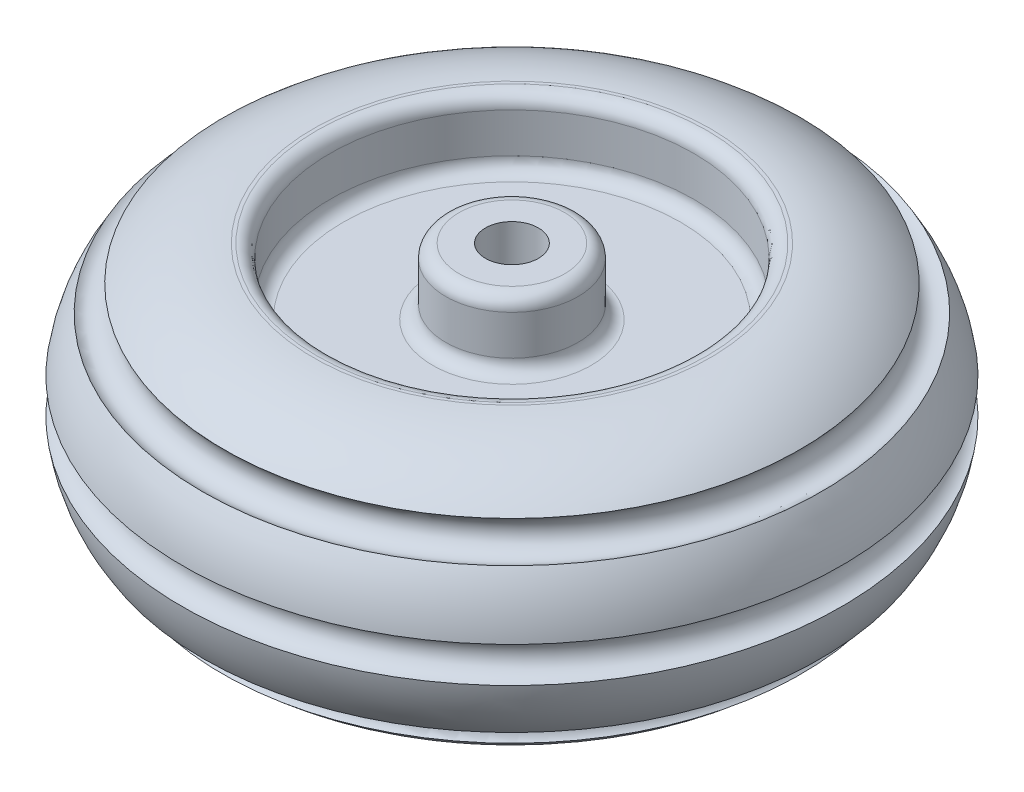
from build123d import *

# Parameters (mm, degrees)
SKETCH3_R          = 20
CUT_EXTRUDE1_DEPTH = 201


with BuildPart() as part:
    # Sketch2 → Revolve2 (revolve)
    with BuildSketch(Plane.XY):
        with BuildLine():
            Line((22.5, -100), (22.5, 100))
            Line((22.5, 100), (62.5, 100))
            ThreePointArc((62.5, 100), (69.571067812, 97.071067812), (72.5, 90))
            Line((72.5, 90), (72.5, 60))
            ThreePointArc((72.5, 60), (75.428932188, 52.928932188), (82.5, 50))
            Line((82.5, 50), (150, 50))
            ThreePointArc((150, 50), (157.071067812, 52.928932188), (160, 60))
            Line((160, 60), (160, 90))
            ThreePointArc((160, 90), (162.928932188, 97.071067812), (170, 100))
            Line((170, 100), (172.5, 100))
            ThreePointArc((172.5, 100), (208.79312261, 93.181592878), (240.137019506, 73.656185024))
            ThreePointArc((240.137019506, 73.656185024), (239.224189112, 56.321788112), (256.465809119, 54.311535598))
            ThreePointArc((256.465809119, 54.311535598), (266.282028137, 34.712118899), (271.592064868, 13.444801233))
            ThreePointArc((271.592064868, 13.444801233), (259.024576949, 0), (271.592064868, -13.444801233))
            ThreePointArc((271.592064868, -13.444801233), (266.054377043, -35.321077788), (255.752549862, -55.398672742))
            ThreePointArc((255.752549862, -55.398672742), (240.215980432, -57.15895768), (241.088983938, -72.770538561))
            ThreePointArc((241.088983938, -72.770538561), (209.39814456, -92.943676106), (172.5, -100))
            Line((172.5, -100), (170, -100))
            ThreePointArc((170, -100), (162.928932188, -97.071067812), (160, -90))
            Line((160, -90), (160, -60))
            ThreePointArc((160, -60), (157.071067812, -52.928932188), (150, -50))
            Line((150, -50), (82.5, -50))
            ThreePointArc((82.5, -50), (75.428932188, -52.928932188), (72.5, -60))
            Line((72.5, -60), (72.5, -90))
            ThreePointArc((72.5, -90), (69.571067812, -97.071067812), (62.5, -100))
            Line((62.5, -100), (22.5, -100))
        make_face()
    revolve(axis=Axis((22.5, -100, 0), (0, 1, 0)))

    # Sketch3 → Cut-Extrude1 (cut, through all)
    with BuildSketch(Plane.XZ.offset(100)):
        with Locations((22.5, 0)):
            Circle(SKETCH3_R)
    extrude(amount=-CUT_EXTRUDE1_DEPTH, mode=Mode.SUBTRACT)


solid = part.part
